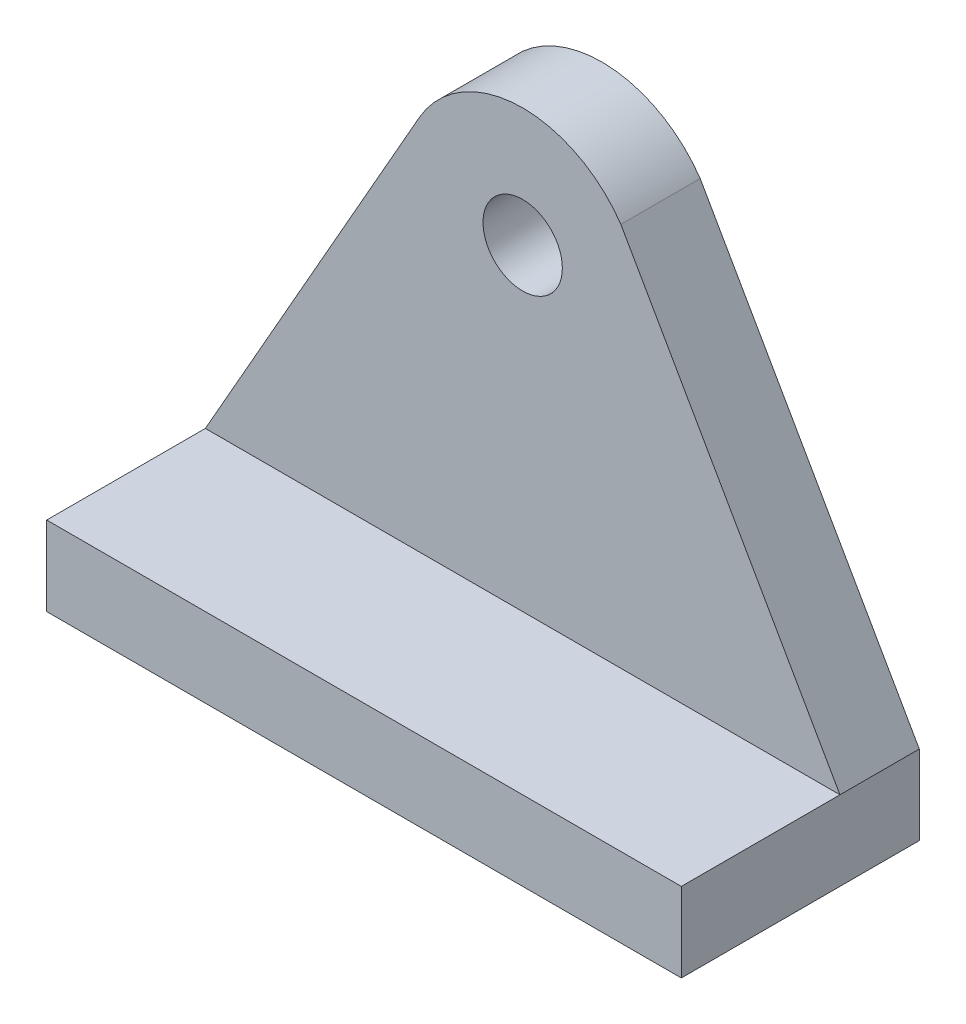
from build123d import *

# Parameters (mm, degrees)
EXTRUDE_1_DEPTH = 2
SKETCH_2_W      = 16
SKETCH_2_H      = 2
EXTRUDE_2_DEPTH = 6


with BuildPart() as part:
    # 草图1 → 凸台-拉伸1 (new body)
    with BuildSketch(Plane.XY):
        with BuildLine():
            Line((-8, -8), (0, -8))
            Line((0, -8), (8, -8))
            Line((8, -8), (2.719740406, 1.26610115))
            Line((2.719740406, 1.26610115), (2.475636513, 1.694468606))
            ThreePointArc((2.475636513, 1.694468606), (-0.124757283, 2.997404814), (-2.607883521, 1.482883521))
            Line((-2.607883521, 1.482883521), (-8, -8))
        make_face()
        with BuildLine():
            ThreePointArc((0, -1), (-0.707106781, 0.707106781), (1, 0))
            ThreePointArc((1, 0), (0.707106781, -0.707106781), (0, -1))
        make_face(mode=Mode.SUBTRACT)
    extrude(amount=EXTRUDE_1_DEPTH)

    # 草图2 → 凸台-拉伸2 (add)
    with BuildSketch(Plane(origin=(0, 0, 0), x_dir=(-1, 0, 0), z_dir=(0, 0, -1))):
        with Locations((0, -9)):
            Rectangle(SKETCH_2_W, SKETCH_2_H)
    extrude(amount=-EXTRUDE_2_DEPTH)


solid = part.part
